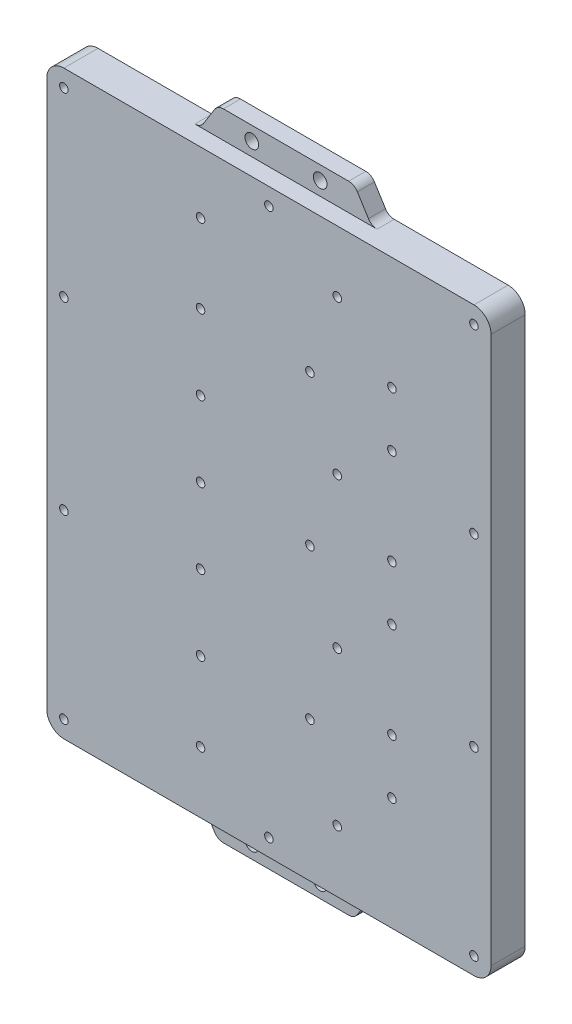
from build123d import *

# Parameters (mm, degrees)
SKETCH1_R           = 2
BOSS_EXTRUDE1_DEPTH = 5
BOSS_EXTRUDE2_DEPTH = 5
SKETCH3_R           = 1.25
CUT_EXTRUDE1_DEPTH  = 5


with BuildPart() as part:
    # Sketch1 → Boss-Extrude1 (new body)
    with BuildSketch(Plane.XY):
        with BuildLine():
            Line((-60, -85), (-26.662742925, -85))
            ThreePointArc((-26.662742925, -85), (-25.208437327, -85.376072556), (-24.118748013, -86.41000318))
            Line((-24.118748013, -86.41000318), (-20.881251987, -91.58999682))
            ThreePointArc((-20.881251987, -91.58999682), (-19.791562673, -92.623927444), (-18.337257075, -93))
            Line((-18.337257075, -93), (18.337257075, -93))
            ThreePointArc((18.337257075, -93), (19.791562673, -92.623927444), (20.881251987, -91.58999682))
            Line((20.881251987, -91.58999682), (24.118748013, -86.41000318))
            ThreePointArc((24.118748013, -86.41000318), (25.208437327, -85.376072556), (26.662742925, -85))
            Line((26.662742925, -85), (60, -85))
            ThreePointArc((60, -85), (63.535533906, -83.535533906), (65, -80))
            Line((65, -80), (65, 80))
            ThreePointArc((65, 80), (63.535533906, 83.535533906), (60, 85))
            Line((60, 85), (26.662742925, 85))
            ThreePointArc((26.662742925, 85), (25.208437327, 85.376072556), (24.118748013, 86.41000318))
            Line((24.118748013, 86.41000318), (20.881251987, 91.58999682))
            ThreePointArc((20.881251987, 91.58999682), (19.791562673, 92.623927444), (18.337257075, 93))
            Line((18.337257075, 93), (-18.337257075, 93))
            ThreePointArc((-18.337257075, 93), (-19.791562673, 92.623927444), (-20.881251987, 91.58999682))
            Line((-20.881251987, 91.58999682), (-24.118748013, 86.41000318))
            ThreePointArc((-24.118748013, 86.41000318), (-25.208437327, 85.376072556), (-26.662742925, 85))
            Line((-26.662742925, 85), (-60, 85))
            ThreePointArc((-60, 85), (-63.535533906, 83.535533906), (-65, 80))
            Line((-65, 80), (-65, -80))
            ThreePointArc((-65, -80), (-63.535533906, -83.535533906), (-60, -85))
        make_face()
        with Locations((-10, 89)):
            Circle(SKETCH1_R, mode=Mode.SUBTRACT)
        with Locations((10, 89)):
            Circle(SKETCH1_R, mode=Mode.SUBTRACT)
        with Locations((10, -89)):
            Circle(SKETCH1_R, mode=Mode.SUBTRACT)
        with Locations((-10, -89)):
            Circle(SKETCH1_R, mode=Mode.SUBTRACT)
    extrude(amount=BOSS_EXTRUDE1_DEPTH)

    # Sketch2 → Boss-Extrude2 (add)
    with BuildSketch(Plane.XY.offset(5)):
        with BuildLine():
            Line((60, -85), (-60, -85))
            ThreePointArc((-60, -85), (-63.535533906, -83.535533906), (-65, -80))
            Line((-65, -80), (-65, 80))
            ThreePointArc((-65, 80), (-63.535533906, 83.535533906), (-60, 85))
            Line((-60, 85), (60, 85))
            ThreePointArc((60, 85), (63.535533906, 83.535533906), (65, 80))
            Line((65, 80), (65, -80))
            ThreePointArc((65, -80), (63.535533906, -83.535533906), (60, -85))
        make_face()
    extrude(amount=BOSS_EXTRUDE2_DEPTH)

    # Sketch3 → Cut-Extrude1 (cut)
    with BuildSketch(Plane.XY.offset(10)):
        with Locations((60, -27)):
            Circle(SKETCH3_R)
        with Locations((60, -80)):
            Circle(SKETCH3_R)
        with Locations((-60, -27)):
            Circle(SKETCH3_R)
        with Locations((-60, -80)):
            Circle(SKETCH3_R)
        with Locations((0, -80)):
            Circle(SKETCH3_R)
        with Locations((60, 27)):
            Circle(SKETCH3_R)
        with Locations((60, 80)):
            Circle(SKETCH3_R)
        with Locations((0, 80)):
            Circle(SKETCH3_R)
        with Locations((-60, 27)):
            Circle(SKETCH3_R)
        with Locations((-60, 80)):
            Circle(SKETCH3_R)
        with Locations((-20, -67)):
            Circle(SKETCH3_R)
        with Locations((-20, -44)):
            Circle(SKETCH3_R)
        with Locations((-20, -22)):
            Circle(SKETCH3_R)
        with Locations((-20, 0)):
            Circle(SKETCH3_R)
        with Locations((-20, 22)):
            Circle(SKETCH3_R)
        with Locations((-20, 44)):
            Circle(SKETCH3_R)
        with Locations((-20, 67)):
            Circle(SKETCH3_R)
        with Locations((36, -52)):
            Circle(SKETCH3_R)
        with Locations((36, -36)):
            Circle(SKETCH3_R)
        with Locations((36, 8)):
            Circle(SKETCH3_R)
        with Locations((36, -8)):
            Circle(SKETCH3_R)
        with Locations((36, 52)):
            Circle(SKETCH3_R)
        with Locations((36, 36)):
            Circle(SKETCH3_R)
        with Locations((20, -67)):
            Circle(SKETCH3_R)
        with Locations((20, -22)):
            Circle(SKETCH3_R)
        with Locations((20, 22)):
            Circle(SKETCH3_R)
        with Locations((20, 67)):
            Circle(SKETCH3_R)
        with Locations((12, -44)):
            Circle(SKETCH3_R)
        with Locations((12, 0)):
            Circle(SKETCH3_R)
        with Locations((12, 44)):
            Circle(SKETCH3_R)
    extrude(amount=-CUT_EXTRUDE1_DEPTH, mode=Mode.SUBTRACT)


solid = part.part
